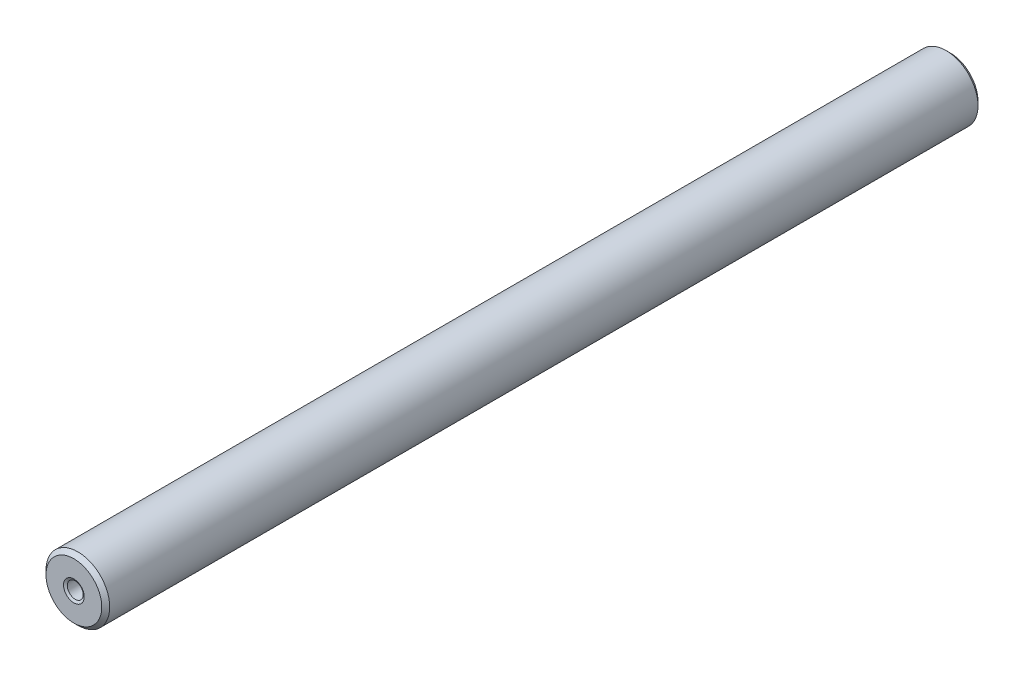
from build123d import *

# Parameters (mm, degrees)
CHAMFER1_SIZE         = 0.5
CHAMFER2_SIZE         = 0.3
CHAMFER2_SIZE2        = 0.173205081
CHAMFER2_PART_2_SIZE  = 0.3
CHAMFER2_PART_2_SIZE2 = 0.173205081
CHAMFER2_PART_3_SIZE  = 0.3
CHAMFER2_PART_3_SIZE2 = 0.173205081
CHAMFER2_PART_4_SIZE  = 0.3
CHAMFER2_PART_4_SIZE2 = 0.173205081


with BuildPart() as part:
    # Sketch1 → Revolve1 (revolve)
    with BuildSketch(Plane(origin=(0, 0, 0), x_dir=(1, 0, 0), z_dir=(0, 1, 0))):
        Polygon((-1, 0), (-4, 0), (-4, -110), (-1, -110), (-1, -108), (0, -108), (0, -2), (-1, -2), align=None)
    revolve(axis=Axis((0, 0, 108), (0, 0, -1)))

    # Chamfer1
    chamfer1_edges = [part.edges().sort_by_distance(p)[0] for p in [
        (4, 0, 110),
        (4, 0, 0),
    ]]
    chamfer(chamfer1_edges, length=CHAMFER1_SIZE)

    # Chamfer2
    chamfer2_edges = [part.edges().sort_by_distance(p)[0] for p in [
        (1, 0, 2),
    ]]
    chamfer2_side = [part.faces().sort_by_distance(p)[0] for p in [
        (0, 0, 2),
    ]]
    chamfer(chamfer2_edges, length=CHAMFER2_SIZE, length2=CHAMFER2_SIZE2, reference=chamfer2_side[0])

    # Chamfer2 part 2
    chamfer2_part_2_edges = [part.edges().sort_by_distance(p)[0] for p in [
        (1, 0, 108),
    ]]
    chamfer2_part_2_side = [part.faces().sort_by_distance(p)[0] for p in [
        (1, 0, 109),
    ]]
    chamfer(chamfer2_part_2_edges, length=CHAMFER2_PART_2_SIZE, length2=CHAMFER2_PART_2_SIZE2, reference=chamfer2_part_2_side[0])

    # Chamfer2 part 3
    chamfer2_part_3_edges = [part.edges().sort_by_distance(p)[0] for p in [
        (1, 0, 110),
    ]]
    chamfer2_part_3_side = [part.faces().sort_by_distance(p)[0] for p in [
        (3.401005051, 0, 110),
    ]]
    chamfer(chamfer2_part_3_edges, length=CHAMFER2_PART_3_SIZE, length2=CHAMFER2_PART_3_SIZE2, reference=chamfer2_part_3_side[0])

    # Chamfer2 part 4
    chamfer2_part_4_edges = [part.edges().sort_by_distance(p)[0] for p in [
        (1, 0, 0),
    ]]
    chamfer2_part_4_side = [part.faces().sort_by_distance(p)[0] for p in [
        (1, 0, 1),
    ]]
    chamfer(chamfer2_part_4_edges, length=CHAMFER2_PART_4_SIZE, length2=CHAMFER2_PART_4_SIZE2, reference=chamfer2_part_4_side[0])


solid = part.part
